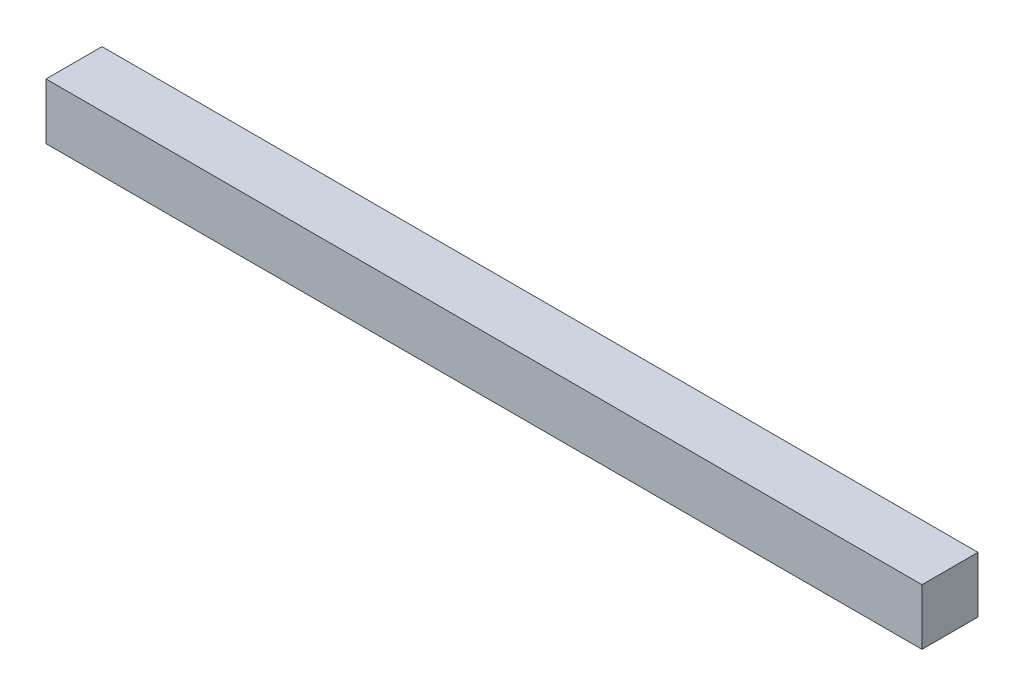
from build123d import *

# Parameters (mm, degrees)
SKETCH1_W           = 46.9
SKETCH1_H           = 3
BOSS_EXTRUDE1_DEPTH = 3


with BuildPart() as part:
    # Sketch1 → Boss-Extrude1 (new body)
    with BuildSketch(Plane(origin=(0, 0, 0), x_dir=(1, 0, 0), z_dir=(0, 1, 0))):
        with Locations((23.45, 1.5)):
            Rectangle(SKETCH1_W, SKETCH1_H)
    extrude(amount=BOSS_EXTRUDE1_DEPTH)


solid = part.part
